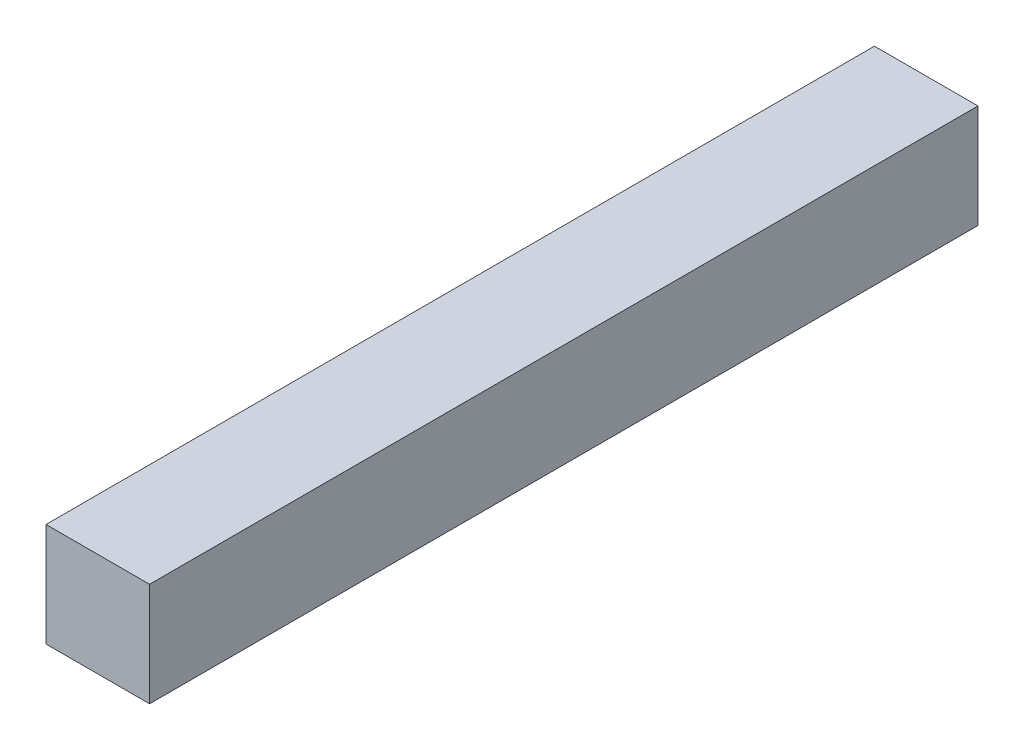
from build123d import *

# Parameters (mm, degrees)
SKETCH1_W           = 25.4
SKETCH1_H           = 25.4
BOSS_EXTRUDE1_DEPTH = 203.2


with BuildPart() as part:
    # Sketch1 → Boss-Extrude1 (new body)
    with BuildSketch(Plane.XY):
        with Locations((12.7, 12.7)):
            Rectangle(SKETCH1_W, SKETCH1_H)
    extrude(amount=BOSS_EXTRUDE1_DEPTH)


solid = part.part
